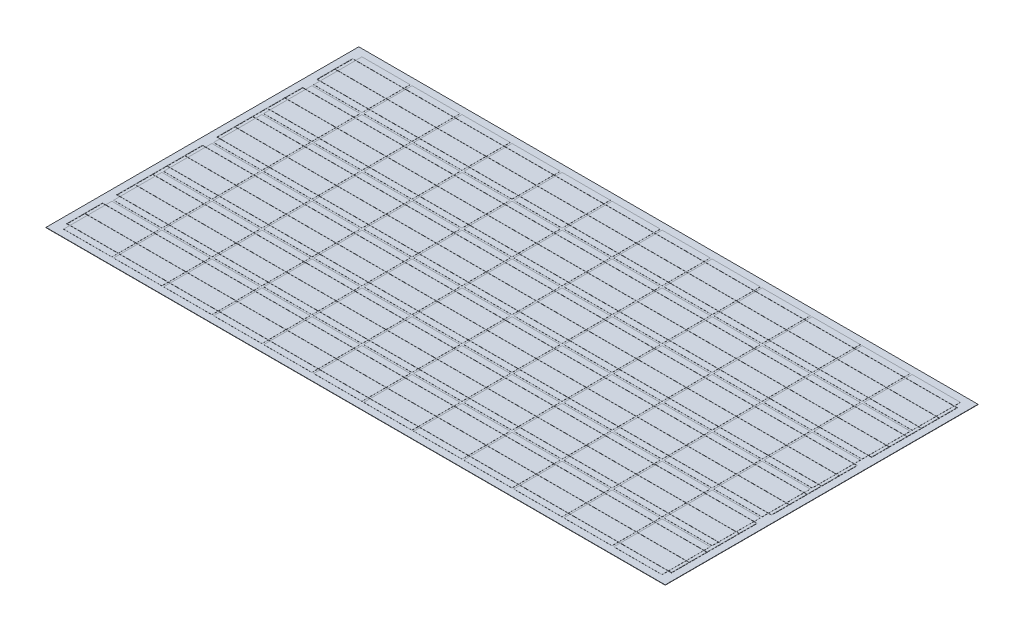
from build123d import *

# Parameters (mm, degrees)
SKETCH1_W           = 152.4
SKETCH1_H           = 152.4
BOSS_EXTRUDE1_DEPTH = 0.3
SKETCH2_W           = 1956
SKETCH2_H           = 988
BOSS_EXTRUDE2_DEPTH = 1
SKETCH5_W           = 85
SKETCH5_H           = 180
BOSS_EXTRUDE3_DEPTH = 20
SKETCH6_R           = 0.25
SKETCH7_W           = 1
SKETCH7_H           = 112.9
SKETCH7_H_2         = 270.9
BOSS_EXTRUDE4_DEPTH = 0.5


with BuildPart() as part:
    # Sketch1 → Boss-Extrude1 (new body)
    with BuildSketch(Plane(origin=(0, 0, 0), x_dir=(1, 0, 0), z_dir=(0, 1, 0))):
        with Locations((158, 0)):
            Rectangle(SKETCH1_W, SKETCH1_H)
        Rectangle(SKETCH1_W, SKETCH1_H)
        with Locations((316, 0)):
            Rectangle(SKETCH1_W, SKETCH1_H)
        with Locations((474, 0)):
            Rectangle(SKETCH1_W, SKETCH1_H)
        with Locations((632, 0)):
            Rectangle(SKETCH1_W, SKETCH1_H)
        with Locations((790, 0)):
            Rectangle(SKETCH1_W, SKETCH1_H)
        with Locations((948, 0)):
            Rectangle(SKETCH1_W, SKETCH1_H)
        with Locations((1106, 0)):
            Rectangle(SKETCH1_W, SKETCH1_H)
        with Locations((1264, 0)):
            Rectangle(SKETCH1_W, SKETCH1_H)
        with Locations((1422, 0)):
            Rectangle(SKETCH1_W, SKETCH1_H)
        with Locations((1580, 0)):
            Rectangle(SKETCH1_W, SKETCH1_H)
        with Locations((1738, 0)):
            Rectangle(SKETCH1_W, SKETCH1_H)
        with Locations((158, 158)):
            Rectangle(SKETCH1_W, SKETCH1_H)
        with Locations((316, 158)):
            Rectangle(SKETCH1_W, SKETCH1_H)
        with Locations((474, 158)):
            Rectangle(SKETCH1_W, SKETCH1_H)
        with Locations((632, 158)):
            Rectangle(SKETCH1_W, SKETCH1_H)
        with Locations((790, 158)):
            Rectangle(SKETCH1_W, SKETCH1_H)
        with Locations((948, 158)):
            Rectangle(SKETCH1_W, SKETCH1_H)
        with Locations((1106, 158)):
            Rectangle(SKETCH1_W, SKETCH1_H)
        with Locations((1264, 158)):
            Rectangle(SKETCH1_W, SKETCH1_H)
        with Locations((1422, 158)):
            Rectangle(SKETCH1_W, SKETCH1_H)
        with Locations((1580, 158)):
            Rectangle(SKETCH1_W, SKETCH1_H)
        with Locations((1738, 158)):
            Rectangle(SKETCH1_W, SKETCH1_H)
        with Locations((158, 316)):
            Rectangle(SKETCH1_W, SKETCH1_H)
        with Locations((316, 316)):
            Rectangle(SKETCH1_W, SKETCH1_H)
        with Locations((474, 316)):
            Rectangle(SKETCH1_W, SKETCH1_H)
        with Locations((632, 316)):
            Rectangle(SKETCH1_W, SKETCH1_H)
        with Locations((790, 316)):
            Rectangle(SKETCH1_W, SKETCH1_H)
        with Locations((948, 316)):
            Rectangle(SKETCH1_W, SKETCH1_H)
        with Locations((1106, 316)):
            Rectangle(SKETCH1_W, SKETCH1_H)
        with Locations((1264, 316)):
            Rectangle(SKETCH1_W, SKETCH1_H)
        with Locations((1422, 316)):
            Rectangle(SKETCH1_W, SKETCH1_H)
        with Locations((1580, 316)):
            Rectangle(SKETCH1_W, SKETCH1_H)
        with Locations((1738, 316)):
            Rectangle(SKETCH1_W, SKETCH1_H)
        with Locations((158, 474)):
            Rectangle(SKETCH1_W, SKETCH1_H)
        with Locations((316, 474)):
            Rectangle(SKETCH1_W, SKETCH1_H)
        with Locations((474, 474)):
            Rectangle(SKETCH1_W, SKETCH1_H)
        with Locations((632, 474)):
            Rectangle(SKETCH1_W, SKETCH1_H)
        with Locations((790, 474)):
            Rectangle(SKETCH1_W, SKETCH1_H)
        with Locations((948, 474)):
            Rectangle(SKETCH1_W, SKETCH1_H)
        with Locations((1106, 474)):
            Rectangle(SKETCH1_W, SKETCH1_H)
        with Locations((1264, 474)):
            Rectangle(SKETCH1_W, SKETCH1_H)
        with Locations((1422, 474)):
            Rectangle(SKETCH1_W, SKETCH1_H)
        with Locations((1580, 474)):
            Rectangle(SKETCH1_W, SKETCH1_H)
        with Locations((1738, 474)):
            Rectangle(SKETCH1_W, SKETCH1_H)
        with Locations((158, 632)):
            Rectangle(SKETCH1_W, SKETCH1_H)
        with Locations((316, 632)):
            Rectangle(SKETCH1_W, SKETCH1_H)
        with Locations((474, 632)):
            Rectangle(SKETCH1_W, SKETCH1_H)
        with Locations((632, 632)):
            Rectangle(SKETCH1_W, SKETCH1_H)
        with Locations((790, 632)):
            Rectangle(SKETCH1_W, SKETCH1_H)
        with Locations((948, 632)):
            Rectangle(SKETCH1_W, SKETCH1_H)
        with Locations((1106, 632)):
            Rectangle(SKETCH1_W, SKETCH1_H)
        with Locations((1264, 632)):
            Rectangle(SKETCH1_W, SKETCH1_H)
        with Locations((1422, 632)):
            Rectangle(SKETCH1_W, SKETCH1_H)
        with Locations((1580, 632)):
            Rectangle(SKETCH1_W, SKETCH1_H)
        with Locations((1738, 632)):
            Rectangle(SKETCH1_W, SKETCH1_H)
        with Locations((158, 790)):
            Rectangle(SKETCH1_W, SKETCH1_H)
        with Locations((316, 790)):
            Rectangle(SKETCH1_W, SKETCH1_H)
        with Locations((474, 790)):
            Rectangle(SKETCH1_W, SKETCH1_H)
        with Locations((632, 790)):
            Rectangle(SKETCH1_W, SKETCH1_H)
        with Locations((790, 790)):
            Rectangle(SKETCH1_W, SKETCH1_H)
        with Locations((948, 790)):
            Rectangle(SKETCH1_W, SKETCH1_H)
        with Locations((1106, 790)):
            Rectangle(SKETCH1_W, SKETCH1_H)
        with Locations((1264, 790)):
            Rectangle(SKETCH1_W, SKETCH1_H)
        with Locations((1422, 790)):
            Rectangle(SKETCH1_W, SKETCH1_H)
        with Locations((1580, 790)):
            Rectangle(SKETCH1_W, SKETCH1_H)
        with Locations((1738, 790)):
            Rectangle(SKETCH1_W, SKETCH1_H)
        with Locations((0, 158)):
            Rectangle(SKETCH1_W, SKETCH1_H)
        with Locations((0, 316)):
            Rectangle(SKETCH1_W, SKETCH1_H)
        with Locations((0, 474)):
            Rectangle(SKETCH1_W, SKETCH1_H)
        with Locations((0, 632)):
            Rectangle(SKETCH1_W, SKETCH1_H)
        with Locations((0, 790)):
            Rectangle(SKETCH1_W, SKETCH1_H)
    extrude(amount=BOSS_EXTRUDE1_DEPTH)

    # Sketch2 → Boss-Extrude2 (add)
    with BuildSketch(Plane.XZ):
        with Locations((868.996238638, -395)):
            Rectangle(SKETCH2_W, SKETCH2_H)
    extrude(amount=BOSS_EXTRUDE2_DEPTH)

    # Sketch5 → Boss-Extrude3 (add)
    with BuildSketch(Plane.XZ.offset(1)):
        with Locations((83.496238638, -395)):
            Rectangle(SKETCH5_W, SKETCH5_H)
    extrude(amount=BOSS_EXTRUDE3_DEPTH)

    # Sweep3: sweep along a path in Sketch3
    with BuildLine(Plane(origin=(0, 0.3, 0), x_dir=(1, 0, 0), z_dir=(0, 1, 0))) as sweep3_path:
        Line((-86.2, 0), (1824.2, 0))
    # Sketch6 → Sweep3 (sweep)
    with BuildSketch(Plane.ZY.offset(76.2)):
        with Locations((56.2, 0.3)):
            Circle(SKETCH6_R)
        with Locations((0, 0.3)):
            Circle(SKETCH6_R)
        with Locations((-56.2, 0.3)):
            Circle(SKETCH6_R)
        with Locations((-101.8, 0.3)):
            Circle(SKETCH6_R)
        with Locations((-214.2, 0.3)):
            Circle(SKETCH6_R)
        with Locations((-259.8, 0.3)):
            Circle(SKETCH6_R)
        with Locations((-316, 0.3)):
            Circle(SKETCH6_R)
        with Locations((-158, 0.3)):
            Circle(SKETCH6_R)
        with Locations((-530.2, 0.3)):
            Circle(SKETCH6_R)
        with Locations((-372.2, 0.3)):
            Circle(SKETCH6_R)
        with Locations((-417.8, 0.3)):
            Circle(SKETCH6_R)
        with Locations((-474, 0.3)):
            Circle(SKETCH6_R)
        with Locations((-575.8, 0.3)):
            Circle(SKETCH6_R)
        with Locations((-632, 0.3)):
            Circle(SKETCH6_R)
        with Locations((-688.2, 0.3)):
            Circle(SKETCH6_R)
        with Locations((-733.8, 0.3)):
            Circle(SKETCH6_R)
        with Locations((-790, 0.3)):
            Circle(SKETCH6_R)
        with Locations((-846.2, 0.3)):
            Circle(SKETCH6_R)
    sweep(path=sweep3_path.line)

    # Sketch7 → Boss-Extrude4 (add)
    with BuildSketch(Plane(origin=(0, 0, 0), x_dir=(1, 0, 0), z_dir=(0, 1, 0))):
        with Locations((-85.7, 0)):
            Rectangle(SKETCH7_W, SKETCH7_H)
        with Locations((-85.7, 237)):
            Rectangle(SKETCH7_W, SKETCH7_H_2)
        with Locations((-85.7, 553)):
            Rectangle(SKETCH7_W, SKETCH7_H_2)
        with Locations((-85.7, 790)):
            Rectangle(SKETCH7_W, SKETCH7_H)
        with Locations((1823.7, 711)):
            Rectangle(SKETCH7_W, SKETCH7_H_2)
        with Locations((1823.7, 395)):
            Rectangle(SKETCH7_W, SKETCH7_H_2)
        with Locations((1823.7, 79)):
            Rectangle(SKETCH7_W, SKETCH7_H_2)
    extrude(amount=BOSS_EXTRUDE4_DEPTH)


solid = part.part
